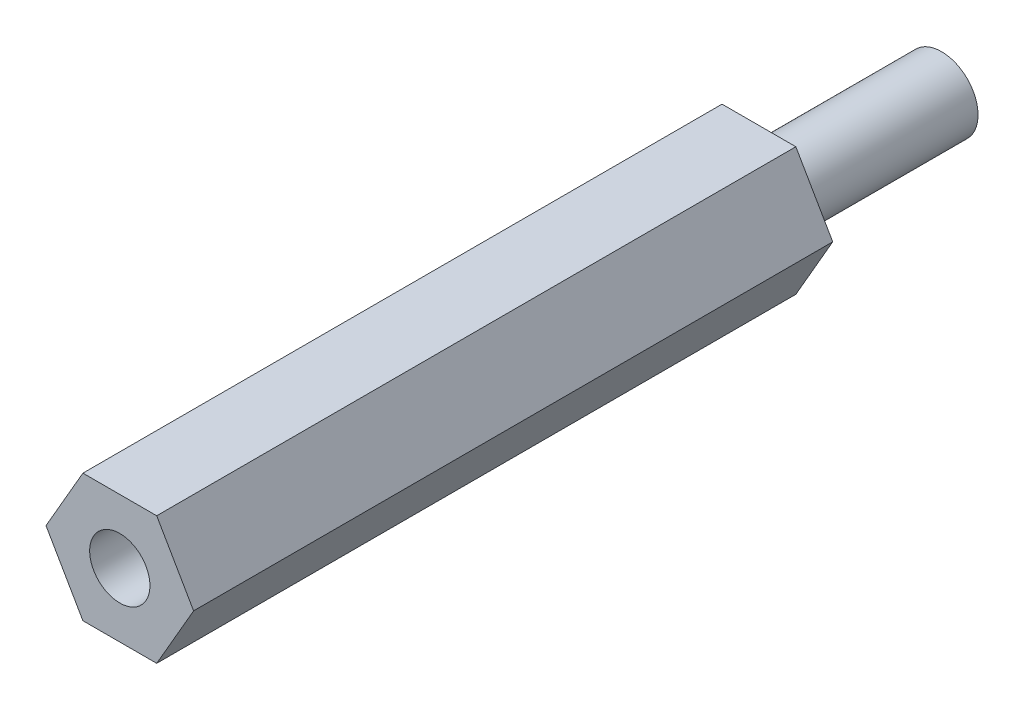
from build123d import *

# Parameters (mm, degrees)
EXTRUDE_1_DEPTH = 35
SKETCH_4_R      = 2
EXTRUDE_2_DEPTH = 10
M4X0_7_1_D      = 3.3
M4X0_7_1_DEPTH  = 10.1
M4X0_7_1_TIP    = 0.991420021


with BuildPart() as part:
    # 草圖1 → 填料-伸長1 (new body)
    with BuildSketch(Plane.XY):
        Polygon((-2.020725942, 3.5), (-4.041451884, 0), (-2.020725942, -3.5), (2.020725942, -3.5), (4.041451884, 0), (2.020725942, 3.5), align=None)
    extrude(amount=EXTRUDE_1_DEPTH)

    # 草圖4 → 填料-伸長2 (add)
    with BuildSketch(Plane(origin=(0, 0, 0), x_dir=(-1, 0, 0), z_dir=(0, 0, -1))):
        Circle(SKETCH_4_R)
    extrude(amount=EXTRUDE_2_DEPTH)

    # M4x0.7 螺紋孔1
    with Locations(Plane.XY.offset(35)):
        with Locations((0, 0)):
            Hole(M4X0_7_1_D / 2, depth=M4X0_7_1_DEPTH)
            with Locations((0, 0, -(M4X0_7_1_DEPTH + M4X0_7_1_TIP / 2))):  # 118° drill point
                Cone(0, M4X0_7_1_D / 2, M4X0_7_1_TIP, mode=Mode.SUBTRACT)


solid = part.part
